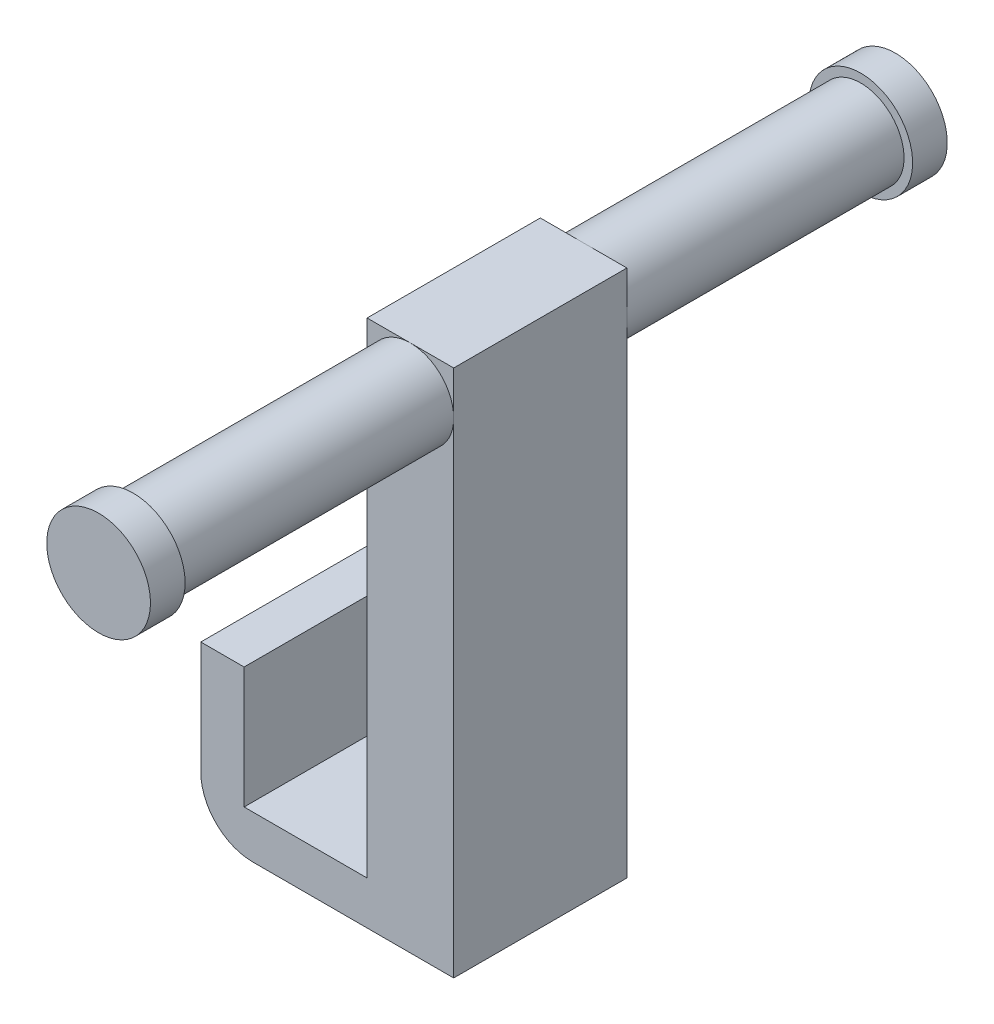
from build123d import *

# Parameters (mm, degrees)
SKETCH1_W           = 5
SKETCH1_H           = 1.25
BOSS_EXTRUDE1_DEPTH = 7.3
SKETCH3_W           = 1.25
SKETCH3_H           = 5
BOSS_EXTRUDE2_DEPTH = 3.5
SKETCH4_W           = 2.5
SKETCH4_H           = 5
BOSS_EXTRUDE3_DEPTH = 14
BOSS_EXTRUDE4_DEPTH = 8
SKETCH6_R           = 1.49705526
BOSS_EXTRUDE5_DEPTH = 1
SKETCH7_R           = 1.25
BOSS_EXTRUDE6_DEPTH = 8
SKETCH8_R           = 1.49705526
BOSS_EXTRUDE7_DEPTH = 1
FILLET2_R           = 1.5


with BuildPart() as part:
    # Sketch1 → Boss-Extrude1 (new body)
    with BuildSketch(Plane(origin=(0, 0, 0), x_dir=(0, 0, -1), z_dir=(1, 0, 0))):
        with Locations((0.720440882, 1.136523046)):
            Rectangle(SKETCH1_W, SKETCH1_H)
    extrude(amount=BOSS_EXTRUDE1_DEPTH)

    # Sketch3 → Boss-Extrude2 (add)
    with BuildSketch(Plane(origin=(0, 1.761523046, 0), x_dir=(1, 0, 0), z_dir=(0, 1, 0))):
        with Locations((0.625, 0.720440882)):
            Rectangle(SKETCH3_W, SKETCH3_H)
    extrude(amount=BOSS_EXTRUDE2_DEPTH)

    # Sketch4 → Boss-Extrude3 (add)
    with BuildSketch(Plane(origin=(0, 1.761523046, 0), x_dir=(1, 0, 0), z_dir=(0, 1, 0))):
        with Locations((6.05, 0.720440882)):
            Rectangle(SKETCH4_W, SKETCH4_H)
    extrude(amount=BOSS_EXTRUDE3_DEPTH)

    # Sketch5 → Boss-Extrude4 (add)
    with BuildSketch(Plane(origin=(0, 0, -3.220440882), x_dir=(-1, 0, 0), z_dir=(0, 0, -1))):
        with BuildLine():
            ThreePointArc((-4.8, 14.511523046), (-5.166116524, 15.395406523), (-6.05, 15.761523046))
            ThreePointArc((-6.05, 15.761523046), (-6.52835429, 15.666372462), (-6.933883476, 15.395406523))
            Line((-6.933883476, 15.395406523), (-5.166116524, 13.62763957))
            ThreePointArc((-5.166116524, 13.62763957), (-4.895150584, 14.033168756), (-4.8, 14.511523046))
        make_face()
        with BuildLine():
            ThreePointArc((-6.933883476, 15.395406523), (-7.20484942, 14.989877325), (-7.3, 14.511523021))
            ThreePointArc((-7.3, 14.511523021), (-6.933883468, 13.627639561), (-6.05, 13.261523046))
            ThreePointArc((-6.05, 13.261523046), (-5.57164571, 13.35667363), (-5.166116524, 13.62763957))
            Line((-5.166116524, 13.62763957), (-6.933883476, 15.395406523))
        make_face()
    extrude(amount=BOSS_EXTRUDE4_DEPTH)

    # Sketch6 → Boss-Extrude5 (add)
    with BuildSketch(Plane(origin=(0, 0, -11.220440882), x_dir=(-1, 0, 0), z_dir=(0, 0, -1))):
        with Locations((-6.05, 14.511523046)):
            Circle(SKETCH6_R)
    extrude(amount=BOSS_EXTRUDE5_DEPTH)

    # Sketch7 → Boss-Extrude6 (add)
    with BuildSketch(Plane.XY.offset(1.779559118)):
        with Locations((6.05, 14.511523046)):
            Circle(SKETCH7_R)
    extrude(amount=BOSS_EXTRUDE6_DEPTH)

    # Sketch8 → Boss-Extrude7 (add)
    with BuildSketch(Plane.XY.offset(9.779559118)):
        with Locations((6.05, 14.511523046)):
            Circle(SKETCH8_R)
    extrude(amount=BOSS_EXTRUDE7_DEPTH)

    # Fillet2
    fillet2_edges = [part.edges().sort_by_distance(p)[0] for p in [
        (0, 0.511523046, -0.720440882),
    ]]
    fillet(fillet2_edges, radius=FILLET2_R)


solid = part.part
